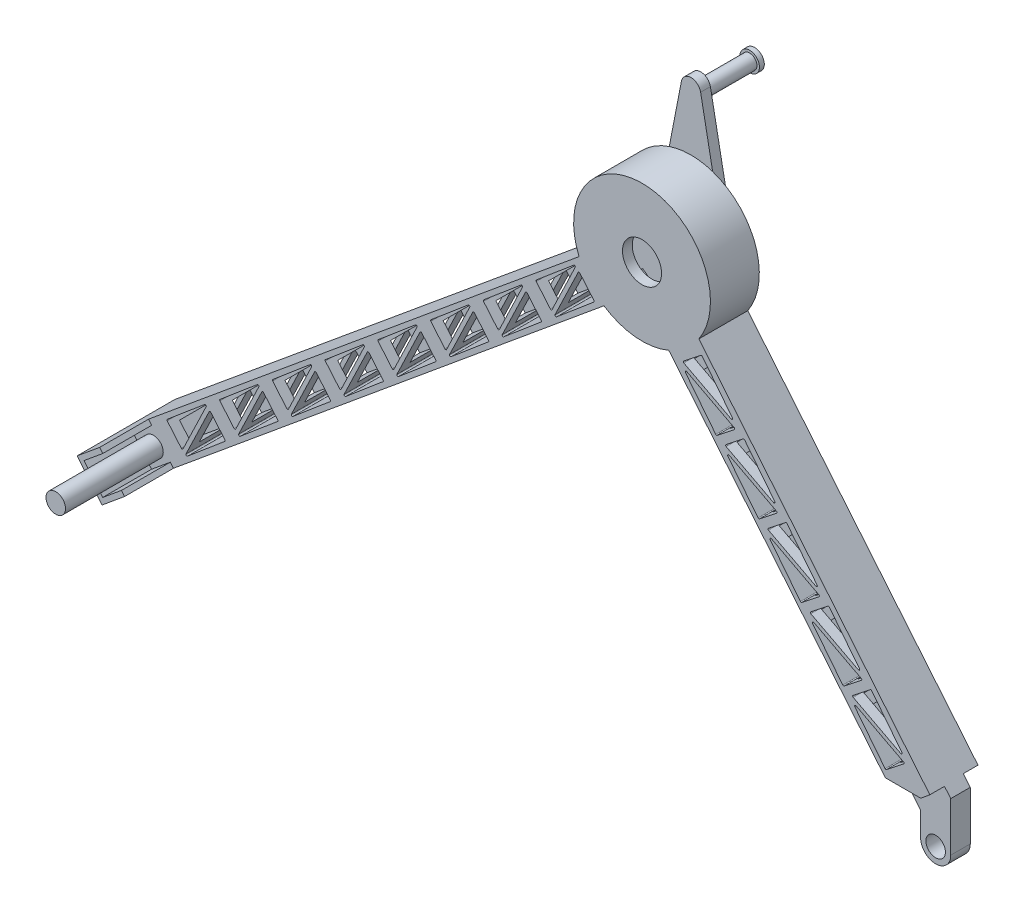
from build123d import *

# Parameters (mm, degrees)
BOSS_EXTRUDE1_DEPTH = 50
SHELL1_T            = -10
BOSS_EXTRUDE2_DEPTH = 50
SKETCH3_R           = 10
CUT_EXTRUDE1_DEPTH  = 50
SKETCH4_W           = 15
SKETCH4_H           = 65.55994612
CUT_EXTRUDE2_DEPTH  = 50
SKETCH6_W           = 14.966774424
SKETCH6_H           = 2.302965467
SKETCH6_W_2         = 15
CUT_EXTRUDE3_DEPTH  = 50
CUT_EXTRUDE4_DEPTH  = 15
CUT_EXTRUDE5_DEPTH  = 15
BOSS_EXTRUDE3_DEPTH = 100
BOSS_EXTRUDE4_DEPTH = 50
CUT_EXTRUDE6_DEPTH  = 100
CUT_EXTRUDE7_DEPTH  = 100
SKETCH13_R          = 10
BOSS_EXTRUDE5_DEPTH = 100
SKETCH15_R          = 20
CUT_EXTRUDE8_DEPTH  = 100
BOSS_EXTRUDE6_DEPTH = 10
SKETCH17_R          = 7.5
BOSS_EXTRUDE7_DEPTH = 50
SKETCH18_R          = 10
BOSS_EXTRUDE8_DEPTH = 5
SKETCH19_R          = 20
CUT_EXTRUDE10_DEPTH = 47


with BuildPart() as part:
    # Sketch1 → Boss-Extrude1 (new body)
    with BuildSketch(Plane.XY):
        with BuildLine():
            Line((-479.217783833, -15.412964144), (-19.435222054, 364.788281099))
            ThreePointArc((-19.435222054, 364.788281099), (12.913875789, 353.262059035), (46.852005688, 358.508130447))
            Line((46.852005688, 358.508130447), (289.564231042, 64.992919372))
            Line((289.564231042, 64.992919372), (320.390159331, 90.483351796))
            Line((320.390159331, 90.483351796), (77.677933976, 383.998562871))
            ThreePointArc((77.677933976, 383.998562871), (26.118554361, 492.637940965), (-44.925654478, 395.614209387))
            Line((-44.925654478, 395.614209387), (-504.708216257, 15.412964144))
            Line((-504.708216257, 15.412964144), (-479.217783833, -15.412964144))
        make_face()
    extrude(amount=BOSS_EXTRUDE1_DEPTH)

    # Shell1
    shell1_openings = [part.faces().sort_by_distance(p)[0] for p in [
        (-491.963000045, 0, 25),
    ]]
    offset(amount=SHELL1_T, openings=shell1_openings, kind=Kind.INTERSECTION)

    # Sketch2 → Boss-Extrude2 (add)
    with BuildSketch(Plane.XY):
        with BuildLine():
            Line((289.564231042, 64.992919372), (289.564231042, 40.336369821))
            ThreePointArc((289.564231042, 40.336369821), (304.977195187, 24.923405676), (320.390159331, 40.336369821))
            Line((320.390159331, 40.336369821), (320.390159331, 90.483351796))
            Line((320.390159331, 90.483351796), (289.564231042, 64.992919372))
        make_face()
    extrude(amount=BOSS_EXTRUDE2_DEPTH)

    # Sketch3 → Cut-Extrude1 (cut)
    with BuildSketch(Plane.XY.offset(50)):
        with Locations((304.977195187, 40.336369821)):
            Circle(SKETCH3_R)
    extrude(amount=-CUT_EXTRUDE1_DEPTH, mode=Mode.SUBTRACT)

    # Sketch4 → Cut-Extrude2 (cut)
    with BuildSketch(Plane(origin=(320.390159331, 0, 0), x_dir=(0, 0, -1), z_dir=(1, 0, 0))):
        with Locations((-42.5, 57.703378736)):
            Rectangle(SKETCH4_W, SKETCH4_H)
        with Locations((-7.5, 57.703378736)):
            Rectangle(SKETCH4_W, SKETCH4_H)
    extrude(amount=-CUT_EXTRUDE2_DEPTH, mode=Mode.SUBTRACT)

    # Sketch6 → Cut-Extrude3 (cut)
    with BuildSketch(Plane(origin=(270.390159331, 0, 0), x_dir=(0, 0, -1), z_dir=(1, 0, 0))):
        with Locations((-42.516612788, 89.331869063)):
            Rectangle(SKETCH6_W, SKETCH6_H)
        with Locations((-7.5, 89.331869063)):
            Rectangle(SKETCH6_W_2, SKETCH6_H)
    extrude(amount=-CUT_EXTRUDE3_DEPTH, mode=Mode.SUBTRACT)

    # Sketch7 → Cut-Extrude4 (cut)
    with BuildSketch(Plane.XY.offset(50)):
        Polygon((304.697997136, 90.483351796), (314.017551224, 98.189833868), (320.390159331, 90.483351796), align=None)
    extrude(amount=-CUT_EXTRUDE4_DEPTH, mode=Mode.SUBTRACT)

    # Sketch8 → Cut-Extrude5 (cut)
    with BuildSketch(Plane(origin=(0, 0, 0), x_dir=(-1, 0, 0), z_dir=(0, 0, -1))):
        Polygon((-304.697997136, 90.483351796), (-313.287427639, 99.072782298), (-320.390159331, 90.483351796), align=None)
    extrude(amount=-CUT_EXTRUDE5_DEPTH, mode=Mode.SUBTRACT)

    # Sketch9 → Boss-Extrude3 (add)
    with BuildSketch(Plane.XY):
        Polygon((-504.708216257, 15.412964144), (-479.217783833, -15.412964144), (-483.071024869, -18.599268197), (-508.561457293, 12.226660091), align=None)
    extrude(amount=BOSS_EXTRUDE3_DEPTH)

    # Sketch10 → Boss-Extrude4 (add)
    with BuildSketch(Plane.XY.offset(50)):
        Polygon((-479.217783833, -15.412964144), (-459.951578653, 0.518556121), (-463.137882706, 4.371797157), (-482.404087886, -11.559723108), align=None)
        Polygon((-504.708216257, 15.412964144), (-485.442011077, 31.344484409), (-482.255707024, 27.491243373), (-501.521912204, 11.559723108), align=None)
    extrude(amount=BOSS_EXTRUDE4_DEPTH)

    # Sketch11 → Cut-Extrude6 (cut)
    with BuildSketch(Plane.XY.offset(50)):
        with BuildLine():
            Line((-426.500288858, 71.882056601), (-450.217471807, 22.46841041))
            ThreePointArc((-450.217471807, 22.46841041), (-450.992493894, 21.909155961), (-451.88307399, 22.25598714))
            Line((-451.88307399, 22.25598714), (-466.369360757, 39.412930127))
            ThreePointArc((-466.369360757, 39.412930127), (-466.601748684, 40.142164169), (-466.250425427, 40.822133585))
            Line((-466.250425427, 40.822133585), (-428.04695571, 73.078836789))
            ThreePointArc((-428.04695571, 73.078836789), (-426.789852871, 73.105649319), (-426.500288858, 71.882056601))
        make_face()
        with BuildLine():
            Line((-407.290306147, 52.064883321), (-421.776592914, 69.221826308))
            ThreePointArc((-421.776592914, 69.221826308), (-422.66717301, 69.568657486), (-423.442195097, 69.009403038))
            Line((-423.442195097, 69.009403038), (-447.159378046, 19.595756847))
            ThreePointArc((-447.159378046, 19.595756847), (-446.869814033, 18.372164128), (-445.612711194, 18.398976658))
            Line((-445.612711194, 18.398976658), (-407.409241477, 50.655679862))
            ThreePointArc((-407.409241477, 50.655679862), (-407.05791822, 51.335649278), (-407.290306147, 52.064883321))
        make_face()
        with BuildLine():
            Line((-372.554914353, 116.490313343), (-396.272097303, 67.076667152))
            ThreePointArc((-396.272097303, 67.076667152), (-397.04711939, 66.517412704), (-397.937699486, 66.864243882))
            Line((-397.937699486, 66.864243882), (-412.423986253, 84.021186869))
            ThreePointArc((-412.423986253, 84.021186869), (-412.65637418, 84.750420912), (-412.305050923, 85.430390327))
            Line((-412.305050923, 85.430390327), (-374.101581206, 117.687093532))
            ThreePointArc((-374.101581206, 117.687093532), (-372.844478367, 117.713906062), (-372.554914353, 116.490313343))
        make_face()
        with BuildLine():
            Line((-391.66733669, 63.007233401), (-353.463866973, 95.263936605))
            ThreePointArc((-353.463866973, 95.263936605), (-353.112543715, 95.943906021), (-353.344931643, 96.673140063))
            Line((-353.344931643, 96.673140063), (-367.83121841, 113.83008305))
            ThreePointArc((-367.83121841, 113.83008305), (-368.721798506, 114.176914229), (-369.496820593, 113.61765978))
            Line((-369.496820593, 113.61765978), (-393.214003542, 64.204013589))
            ThreePointArc((-393.214003542, 64.204013589), (-392.924439528, 62.98042087), (-391.66733669, 63.007233401))
        make_face()
        with BuildLine():
            Line((-318.609539849, 161.098570086), (-342.326722799, 111.684923895))
            ThreePointArc((-342.326722799, 111.684923895), (-343.101744886, 111.125669446), (-343.992324982, 111.472500625))
            Line((-343.992324982, 111.472500625), (-358.478611749, 128.629443612))
            ThreePointArc((-358.478611749, 128.629443612), (-358.710999676, 129.358677654), (-358.359676418, 130.03864707))
            Line((-358.359676418, 130.03864707), (-320.156206702, 162.295350274))
            ThreePointArc((-320.156206702, 162.295350274), (-318.899103863, 162.322162804), (-318.609539849, 161.098570086))
        make_face()
        with BuildLine():
            Line((-337.721962185, 107.615490143), (-299.518492469, 139.872193347))
            ThreePointArc((-299.518492469, 139.872193347), (-299.167169211, 140.552162763), (-299.399557138, 141.281396806))
            Line((-299.399557138, 141.281396806), (-313.885843906, 158.438339793))
            ThreePointArc((-313.885843906, 158.438339793), (-314.776424001, 158.785170971), (-315.551446088, 158.225916523))
            Line((-315.551446088, 158.225916523), (-339.268629038, 108.812270332))
            ThreePointArc((-339.268629038, 108.812270332), (-338.979065024, 107.588677613), (-337.721962185, 107.615490143))
        make_face()
        with BuildLine():
            Line((-264.664165345, 205.706826828), (-288.381348295, 156.293180637))
            ThreePointArc((-288.381348295, 156.293180637), (-289.156370382, 155.733926189), (-290.046950477, 156.080757367))
            Line((-290.046950477, 156.080757367), (-304.533237245, 173.237700354))
            ThreePointArc((-304.533237245, 173.237700354), (-304.765625172, 173.966934397), (-304.414301914, 174.646903812))
            Line((-304.414301914, 174.646903812), (-266.210832198, 206.903607017))
            ThreePointArc((-266.210832198, 206.903607017), (-264.953729359, 206.930419547), (-264.664165345, 205.706826828))
        make_face()
        with BuildLine():
            Line((-283.776587681, 152.223746886), (-245.573117965, 184.48045009))
            ThreePointArc((-245.573117965, 184.48045009), (-245.221794707, 185.160419506), (-245.454182634, 185.889653548))
            Line((-245.454182634, 185.889653548), (-259.940469401, 203.046596535))
            ThreePointArc((-259.940469401, 203.046596535), (-260.831049497, 203.393427714), (-261.606071584, 202.834173265))
            Line((-261.606071584, 202.834173265), (-285.323254534, 153.420527074))
            ThreePointArc((-285.323254534, 153.420527074), (-285.03369052, 152.196934355), (-283.776587681, 152.223746886))
        make_face()
        with BuildLine():
            Line((-210.718790841, 250.315083571), (-234.43597379, 200.90143738))
            ThreePointArc((-234.43597379, 200.90143738), (-235.210995877, 200.342182931), (-236.101575973, 200.68901411))
            Line((-236.101575973, 200.68901411), (-250.58786274, 217.845957097))
            ThreePointArc((-250.58786274, 217.845957097), (-250.820250668, 218.575191139), (-250.46892741, 219.255160555))
            Line((-250.46892741, 219.255160555), (-212.265457693, 251.511863759))
            ThreePointArc((-212.265457693, 251.511863759), (-211.008354855, 251.538676289), (-210.718790841, 250.315083571))
        make_face()
        with BuildLine():
            Line((-229.831213177, 196.832003628), (-191.62774346, 229.088706832))
            ThreePointArc((-191.62774346, 229.088706832), (-191.276420203, 229.768676248), (-191.50880813, 230.497910291))
            Line((-191.50880813, 230.497910291), (-205.995094897, 247.654853278))
            ThreePointArc((-205.995094897, 247.654853278), (-206.885674993, 248.001684456), (-207.66069708, 247.442430008))
            Line((-207.66069708, 247.442430008), (-231.37788003, 198.028783817))
            ThreePointArc((-231.37788003, 198.028783817), (-231.088316016, 196.805191098), (-229.831213177, 196.832003628))
        make_face()
        with BuildLine():
            Line((-156.773416337, 294.923340313), (-180.490599286, 245.509694122))
            ThreePointArc((-180.490599286, 245.509694122), (-181.265621373, 244.950439674), (-182.156201469, 245.297270852))
            Line((-182.156201469, 245.297270852), (-196.642488236, 262.454213839))
            ThreePointArc((-196.642488236, 262.454213839), (-196.874876163, 263.183447882), (-196.523552906, 263.863417297))
            Line((-196.523552906, 263.863417297), (-158.320083189, 296.120120502))
            ThreePointArc((-158.320083189, 296.120120502), (-157.06298035, 296.146933032), (-156.773416337, 294.923340313))
        make_face()
        with BuildLine():
            Line((-175.885838673, 241.440260371), (-137.682368956, 273.696963575))
            ThreePointArc((-137.682368956, 273.696963575), (-137.331045699, 274.376932991), (-137.563433626, 275.106167033))
            Line((-137.563433626, 275.106167033), (-152.049720393, 292.26311002))
            ThreePointArc((-152.049720393, 292.26311002), (-152.940300489, 292.609941199), (-153.715322576, 292.05068675))
            Line((-153.715322576, 292.05068675), (-177.432505525, 242.637040559))
            ThreePointArc((-177.432505525, 242.637040559), (-177.142941512, 241.41344784), (-175.885838673, 241.440260371))
        make_face()
        with BuildLine():
            Line((-102.828041833, 339.531597056), (-126.545224782, 290.117950865))
            ThreePointArc((-126.545224782, 290.117950865), (-127.320246869, 289.558696416), (-128.210826965, 289.905527595))
            Line((-128.210826965, 289.905527595), (-142.697113732, 307.062470582))
            ThreePointArc((-142.697113732, 307.062470582), (-142.929501659, 307.791704624), (-142.578178402, 308.47167404))
            Line((-142.578178402, 308.47167404), (-104.374708685, 340.728377244))
            ThreePointArc((-104.374708685, 340.728377244), (-103.117605846, 340.755189774), (-102.828041833, 339.531597056))
        make_face()
        with BuildLine():
            Line((-121.940464169, 286.048517113), (-83.736994452, 318.305220317))
            ThreePointArc((-83.736994452, 318.305220317), (-83.385671195, 318.985189733), (-83.618059122, 319.714423776))
            Line((-83.618059122, 319.714423776), (-98.104345889, 336.871366763))
            ThreePointArc((-98.104345889, 336.871366763), (-98.994925985, 337.218197941), (-99.769948072, 336.658943493))
            Line((-99.769948072, 336.658943493), (-123.487131021, 287.245297302))
            ThreePointArc((-123.487131021, 287.245297302), (-123.197567008, 286.021704583), (-121.940464169, 286.048517113))
        make_face()
        with BuildLine():
            Line((-67.995089665, 330.656773856), (-29.791619948, 362.91347706))
            ThreePointArc((-29.791619948, 362.91347706), (-29.44029669, 363.593446476), (-29.672684618, 364.322680518))
            Line((-29.672684618, 364.322680518), (-44.158971385, 381.479623505))
            ThreePointArc((-44.158971385, 381.479623505), (-45.049551481, 381.826454684), (-45.824573568, 381.267200235))
            Line((-45.824573568, 381.267200235), (-69.541756517, 331.853554044))
            ThreePointArc((-69.541756517, 331.853554044), (-69.252192503, 330.629961325), (-67.995089665, 330.656773856))
        make_face()
        with BuildLine():
            Line((-48.882667328, 384.139853798), (-72.599850278, 334.726207607))
            ThreePointArc((-72.599850278, 334.726207607), (-73.374872365, 334.166953159), (-74.265452461, 334.513784337))
            Line((-74.265452461, 334.513784337), (-88.751739228, 351.670727324))
            ThreePointArc((-88.751739228, 351.670727324), (-88.984127155, 352.399961367), (-88.632803898, 353.079930782))
            Line((-88.632803898, 353.079930782), (-50.429334181, 385.336633987))
            ThreePointArc((-50.429334181, 385.336633987), (-49.172231342, 385.363446517), (-48.882667328, 384.139853798))
        make_face()
    extrude(amount=-CUT_EXTRUDE6_DEPTH, mode=Mode.SUBTRACT)

    # Sketch12 → Cut-Extrude7 (cut)
    with BuildSketch(Plane.XY.offset(50)):
        with BuildLine():
            Line((269.658956116, 98.279327103), (287.293610963, 112.180123676))
            ThreePointArc((287.293610963, 112.180123676), (287.670211511, 113.058529505), (287.137351256, 113.851930238))
            Line((287.137351256, 113.851930238), (238.549707795, 139.218327299))
            ThreePointArc((238.549707795, 139.218327299), (237.317064826, 138.970098033), (237.301563858, 137.712804838))
            Line((237.301563858, 137.712804838), (268.254552471, 98.445611203))
            ThreePointArc((268.254552471, 98.445611203), (268.922315729, 98.071607635), (269.658956116, 98.279327103))
        make_face()
        with BuildLine():
            Line((254.452882758, 160.692549883), (285.405871372, 121.425356249))
            ThreePointArc((285.405871372, 121.425356249), (285.390370404, 120.168063053), (284.157727434, 119.919833787))
            Line((284.157727434, 119.919833787), (235.570083973, 145.286230848))
            ThreePointArc((235.570083973, 145.286230848), (235.037223718, 146.079631581), (235.413824266, 146.95803741))
            Line((235.413824266, 146.95803741), (253.048479113, 160.858833983))
            ThreePointArc((253.048479113, 160.858833983), (253.785119501, 161.066553451), (254.452882758, 160.692549883))
        make_face()
        with BuildLine():
            Line((192.080089145, 199.3621155), (209.714743992, 213.262912073))
            ThreePointArc((209.714743992, 213.262912073), (210.451384379, 213.470631541), (211.119147637, 213.096627973))
            Line((211.119147637, 213.096627973), (242.07213625, 173.829434338))
            ThreePointArc((242.07213625, 173.829434338), (242.056635282, 172.572141143), (240.823992313, 172.323911877))
            Line((240.823992313, 172.323911877), (192.236348852, 197.690308938))
            ThreePointArc((192.236348852, 197.690308938), (191.703488597, 198.483709671), (192.080089145, 199.3621155))
        make_face()
        with BuildLine():
            Line((193.967828736, 190.116882927), (224.92081735, 150.849689293))
            ThreePointArc((224.92081735, 150.849689293), (225.588580607, 150.475685725), (226.325220995, 150.683405193))
            Line((226.325220995, 150.683405193), (243.959875842, 164.584201766))
            ThreePointArc((243.959875842, 164.584201766), (244.336476389, 165.462607595), (243.803616135, 166.256008328))
            Line((243.803616135, 166.256008328), (195.215972674, 191.622405389))
            ThreePointArc((195.215972674, 191.622405389), (193.983329704, 191.374176123), (193.967828736, 190.116882927))
        make_face()
        with BuildLine():
            Line((148.746354023, 251.76619359), (166.381008871, 265.666990163))
            ThreePointArc((166.381008871, 265.666990163), (167.117649258, 265.874709631), (167.785412516, 265.500706062))
            Line((167.785412516, 265.500706062), (198.738401129, 226.233512428))
            ThreePointArc((198.738401129, 226.233512428), (198.722900161, 224.976219233), (197.490257191, 224.727989967))
            Line((197.490257191, 224.727989967), (148.90261373, 250.094387028))
            ThreePointArc((148.90261373, 250.094387028), (148.369753476, 250.88778776), (148.746354023, 251.76619359))
        make_face()
        with BuildLine():
            Line((150.634093615, 242.520961017), (181.587082228, 203.253767383))
            ThreePointArc((181.587082228, 203.253767383), (182.254845486, 202.879763814), (182.991485873, 203.087483283))
            Line((182.991485873, 203.087483283), (200.626140721, 216.988279855))
            ThreePointArc((200.626140721, 216.988279855), (201.002741268, 217.866685685), (200.469881014, 218.660086417))
            Line((200.469881014, 218.660086417), (151.882237553, 244.026483479))
            ThreePointArc((151.882237553, 244.026483479), (150.649594583, 243.778254212), (150.634093615, 242.520961017))
        make_face()
        with BuildLine():
            Line((105.412618902, 304.17027168), (123.047273749, 318.071068252))
            ThreePointArc((123.047273749, 318.071068252), (123.783914137, 318.278787721), (124.451677394, 317.904784152))
            Line((124.451677394, 317.904784152), (155.404666008, 278.637590518))
            ThreePointArc((155.404666008, 278.637590518), (155.38916504, 277.380297323), (154.15652207, 277.132068056))
            Line((154.15652207, 277.132068056), (105.568878609, 302.498465118))
            ThreePointArc((105.568878609, 302.498465118), (105.036018355, 303.29186585), (105.412618902, 304.17027168))
        make_face()
        with BuildLine():
            Line((107.300358494, 294.925039107), (138.253347107, 255.657845473))
            ThreePointArc((138.253347107, 255.657845473), (138.921110365, 255.283841904), (139.657750752, 255.491561372))
            Line((139.657750752, 255.491561372), (157.292405599, 269.392357945))
            ThreePointArc((157.292405599, 269.392357945), (157.669006147, 270.270763775), (157.136145892, 271.064164507))
            Line((157.136145892, 271.064164507), (108.548502431, 296.430561569))
            ThreePointArc((108.548502431, 296.430561569), (107.315859462, 296.182332302), (107.300358494, 294.925039107))
        make_face()
        with BuildLine():
            Line((62.078883781, 356.574349769), (79.713538628, 370.475146342))
            ThreePointArc((79.713538628, 370.475146342), (80.450179015, 370.68286581), (81.117942273, 370.308862242))
            Line((81.117942273, 370.308862242), (112.070930887, 331.041668608))
            ThreePointArc((112.070930887, 331.041668608), (112.055429918, 329.784375412), (110.822786949, 329.536146146))
            Line((110.822786949, 329.536146146), (62.235143488, 354.902543207))
            ThreePointArc((62.235143488, 354.902543207), (61.702283233, 355.69594394), (62.078883781, 356.574349769))
        make_face()
        with BuildLine():
            Line((63.966623372, 347.329117197), (94.919611986, 308.061923562))
            ThreePointArc((94.919611986, 308.061923562), (95.587375243, 307.687919994), (96.324015631, 307.895639462))
            Line((96.324015631, 307.895639462), (113.958670478, 321.796436035))
            ThreePointArc((113.958670478, 321.796436035), (114.335271026, 322.674841864), (113.802410771, 323.468242597))
            Line((113.802410771, 323.468242597), (65.21476731, 348.834639658))
            ThreePointArc((65.21476731, 348.834639658), (63.982124341, 348.586410392), (63.966623372, 347.329117197))
        make_face()
    extrude(amount=-CUT_EXTRUDE7_DEPTH, mode=Mode.SUBTRACT)

    # Sketch13 → Boss-Extrude5 (add)
    with BuildSketch(Plane.XY.offset(50)):
        with Locations((-480.403276937, 9.558912159)):
            Circle(SKETCH13_R)
    extrude(amount=BOSS_EXTRUDE5_DEPTH)

    # Sketch15 → Cut-Extrude8 (cut)
    with BuildSketch(Plane(origin=(0, 0, 0), x_dir=(-1, 0, 0), z_dir=(0, 0, -1))):
        with Locations((-19.516215075, 422.95)):
            Circle(SKETCH15_R)
    extrude(amount=-CUT_EXTRUDE8_DEPTH, mode=Mode.SUBTRACT)

    # Sketch16 → Boss-Extrude6 (add)
    with BuildSketch(Plane(origin=(0, 0, 0), x_dir=(-1, 0, 0), z_dir=(0, 0, -1))):
        with BuildLine():
            Line((-29.463279428, 553.456710819), (-52.02831367, 435.910071178))
            ThreePointArc((-52.02831367, 435.910071178), (-19.45086626, 387.950061007), (12.947261193, 436.03138787))
            Line((12.947261193, 436.03138787), (-9.825446373, 553.475043823))
            ThreePointArc((-9.825446373, 553.475043823), (-19.651929913, 561.571462482), (-29.463279428, 553.456710819))
        make_face()
    extrude(amount=BOSS_EXTRUDE6_DEPTH)

    # Sketch17 → Boss-Extrude7 (add)
    with BuildSketch(Plane(origin=(0, 0, -10), x_dir=(-1, 0, 0), z_dir=(0, 0, -1))):
        with Locations((-19.635176165, 545.80487066)):
            Circle(SKETCH17_R)
    extrude(amount=BOSS_EXTRUDE7_DEPTH)

    # Sketch18 → Boss-Extrude8 (add)
    with BuildSketch(Plane(origin=(0, 0, -60), x_dir=(-1, 0, 0), z_dir=(0, 0, -1))):
        with Locations((-19.635176165, 545.80487066)):
            Circle(SKETCH18_R)
    extrude(amount=BOSS_EXTRUDE8_DEPTH)

    # Sketch19 → Cut-Extrude10 (cut)
    with BuildSketch(Plane.XY):
        with Locations((19.516215075, 422.95)):
            Circle(SKETCH19_R)
    extrude(amount=-CUT_EXTRUDE10_DEPTH, mode=Mode.SUBTRACT)


solid = part.part
